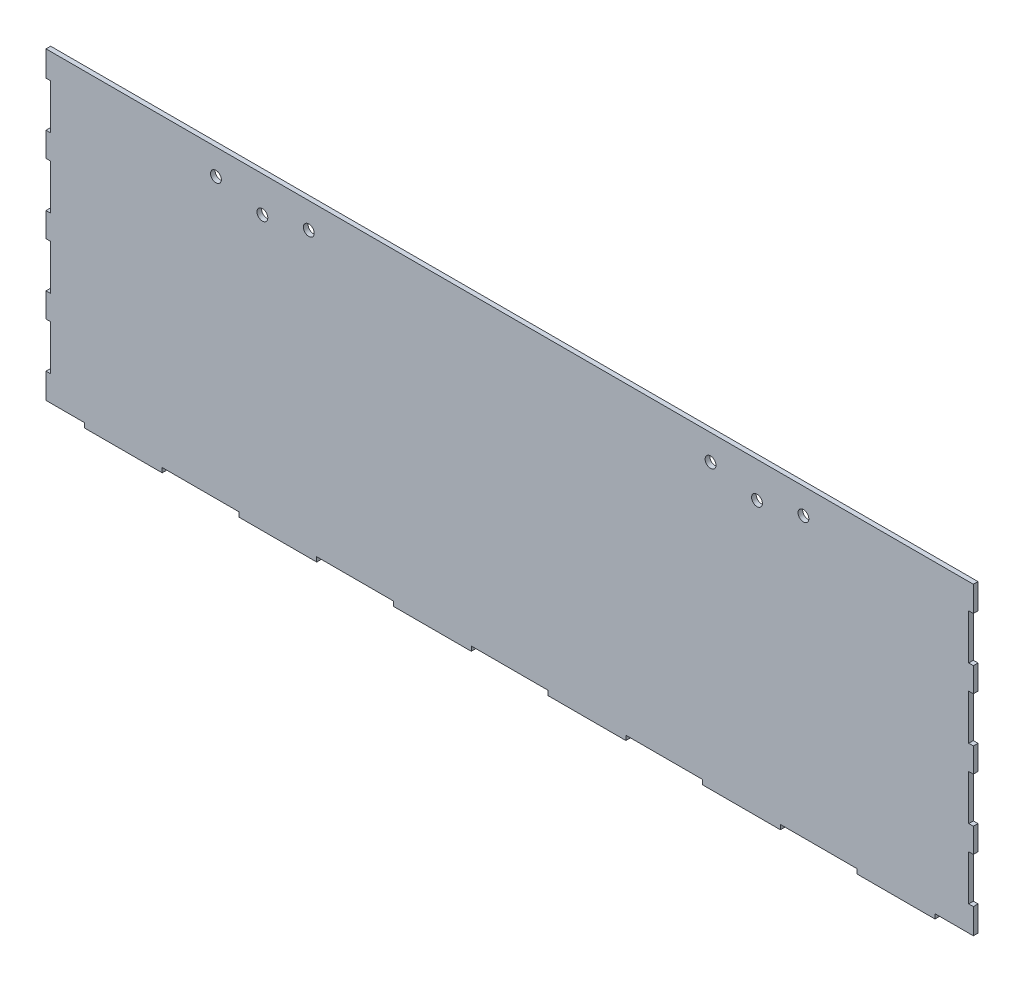
from build123d import *

# Parameters (mm, degrees)
CROQUIS1_W              = 600
CROQUIS1_H              = 200
SALIENTE_EXTRUIR1_DEPTH = 3
CROQUIS2_W              = 3
CROQUIS2_H              = 29.2
CROQUIS2_W_2            = 24.85
CROQUIS2_H_2            = 3
CROQUIS2_W_3            = 49.7
CORTAR_EXTRUIR1_DEPTH   = 4
CORTAR_EXTRUIR2_DEPTH   = 4


with BuildPart() as part:
    # Croquis1 → Saliente-Extruir1 (new body)
    with BuildSketch(Plane.XY):
        Rectangle(CROQUIS1_W, CROQUIS1_H)
    extrude(amount=SALIENTE_EXTRUIR1_DEPTH)

    # Croquis2 → Cortar-Extruir1 (cut, through all)
    with BuildSketch(Plane(origin=(0, 0, 0), x_dir=(-1, 0, 0), z_dir=(0, 0, -1))):
        with Locations((-298.5, 69)):
            Rectangle(CROQUIS2_W, CROQUIS2_H)
        with Locations((298.5, 69)):
            Rectangle(CROQUIS2_W, CROQUIS2_H)
        with Locations((-298.5, 24)):
            Rectangle(CROQUIS2_W, CROQUIS2_H)
        with Locations((298.5, 24)):
            Rectangle(CROQUIS2_W, CROQUIS2_H)
        with Locations((-298.5, -21)):
            Rectangle(CROQUIS2_W, CROQUIS2_H)
        with Locations((298.5, -21)):
            Rectangle(CROQUIS2_W, CROQUIS2_H)
        with Locations((-298.5, -66)):
            Rectangle(CROQUIS2_W, CROQUIS2_H)
        with Locations((298.5, -66)):
            Rectangle(CROQUIS2_W, CROQUIS2_H)
        with Locations((-287.575, -98.5)):
            Rectangle(CROQUIS2_W_2, CROQUIS2_H_2)
        with Locations((287.575, -98.5)):
            Rectangle(CROQUIS2_W_2, CROQUIS2_H_2)
        with Locations((-200, -98.5)):
            Rectangle(CROQUIS2_W_3, CROQUIS2_H_2)
        with Locations((200, -98.5)):
            Rectangle(CROQUIS2_W_3, CROQUIS2_H_2)
        with Locations((-100, -98.5)):
            Rectangle(CROQUIS2_W_3, CROQUIS2_H_2)
        with Locations((100, -98.5)):
            Rectangle(CROQUIS2_W_3, CROQUIS2_H_2)
        with Locations((0, -98.5)):
            Rectangle(CROQUIS2_W_3, CROQUIS2_H_2)
    extrude(amount=-CORTAR_EXTRUIR1_DEPTH, mode=Mode.SUBTRACT)

    # Croquis3 → Cortar-Extruir2 (cut, through all)
    with BuildSketch(Plane.XY.offset(3)):
        with BuildLine():
            ThreePointArc((-163.5, 77), (-160, 73.5), (-156.5, 77))
            ThreePointArc((-156.5, 77), (-160, 80.5), (-163.5, 77))
        make_face()
        with BuildLine():
            ThreePointArc((-133.45, 83.4), (-129.95, 79.9), (-126.45, 83.4))
            ThreePointArc((-126.45, 83.4), (-129.95, 86.9), (-133.45, 83.4))
        make_face()
        with BuildLine():
            ThreePointArc((126.45, 83.4), (129.95, 79.9), (133.45, 83.4))
            ThreePointArc((133.45, 83.4), (129.95, 86.9), (126.45, 83.4))
        make_face()
        with BuildLine():
            ThreePointArc((156.5, 77), (160, 73.5), (163.5, 77))
            ThreePointArc((163.5, 77), (160, 80.5), (156.5, 77))
        make_face()
        with BuildLine():
            ThreePointArc((186.55, 83.4), (190.05, 79.9), (193.55, 83.4))
            ThreePointArc((193.55, 83.4), (190.05, 86.9), (186.55, 83.4))
        make_face()
        with BuildLine():
            ThreePointArc((-193.55, 83.4), (-190.05, 79.9), (-186.55, 83.4))
            ThreePointArc((-186.55, 83.4), (-190.05, 86.9), (-193.55, 83.4))
        make_face()
    extrude(amount=-CORTAR_EXTRUIR2_DEPTH, mode=Mode.SUBTRACT)


solid = part.part
